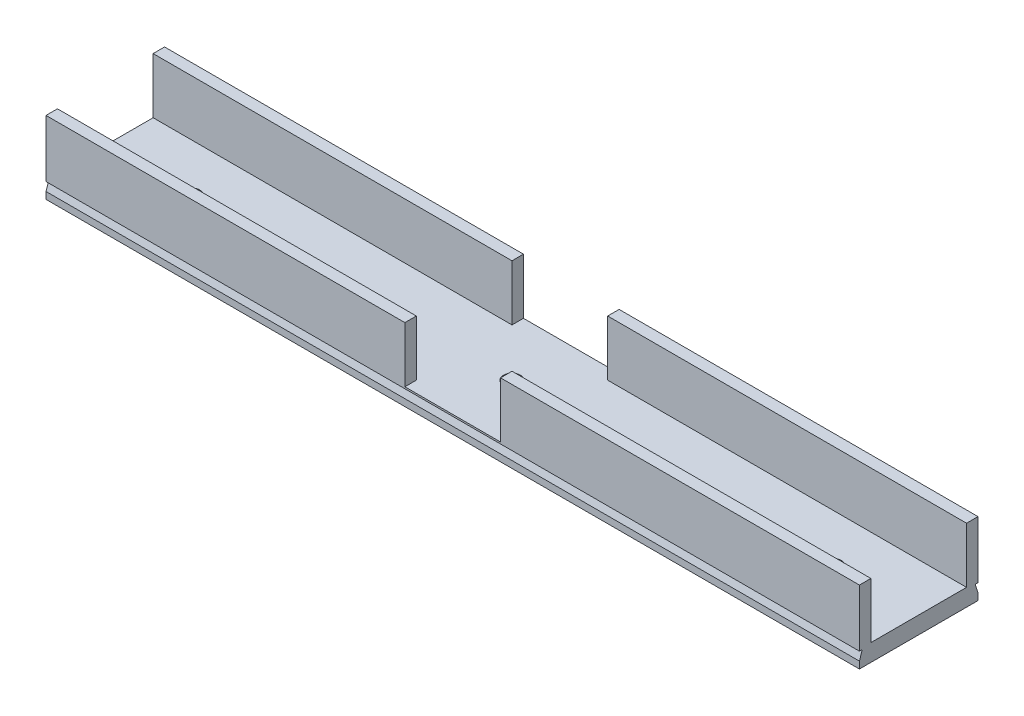
from build123d import *

# Parameters (mm, degrees)
CROQUIS1_W              = 142
CROQUIS1_H              = 20.7
SALIENTE_EXTRUIR2_DEPTH = 3
CROQUIS6_R              = 1.5
CORTAR_EXTRUIR4_DEPTH   = 3
CROQUIS7_W              = 142
CROQUIS7_H              = 2
SALIENTE_EXTRUIR3_DEPTH = 9.7
CORTAR_EXTRUIR5_DEPTH   = 224
CROQUIS10_W             = 16.7
CROQUIS10_H             = 9.7
CORTAR_EXTRUIR6_DEPTH   = 80


with BuildPart() as part:
    # Croquis1 → Saliente-Extruir2 (new body)
    with BuildSketch(Plane(origin=(0, 0, 0), x_dir=(1, 0, 0), z_dir=(0, 1, 0))):
        Rectangle(CROQUIS1_W, CROQUIS1_H)
    extrude(amount=SALIENTE_EXTRUIR2_DEPTH)

    # Croquis6 → Cortar-Extruir4 (cut)
    with BuildSketch(Plane(origin=(0, 3, 0), x_dir=(1, 0, 0), z_dir=(0, 1, 0))):
        with Locations((-56, 0)):
            Circle(CROQUIS6_R)
        Circle(CROQUIS6_R)
        with Locations((56, 0)):
            Circle(CROQUIS6_R)
    extrude(amount=-CORTAR_EXTRUIR4_DEPTH, mode=Mode.SUBTRACT)

    # Croquis7 → Saliente-Extruir3 (add)
    with BuildSketch(Plane(origin=(0, 3, 0), x_dir=(1, 0, 0), z_dir=(0, 1, 0))):
        with Locations((0, 9.35)):
            Rectangle(CROQUIS7_W, CROQUIS7_H)
        with Locations((0, -9.35)):
            Rectangle(CROQUIS7_W, CROQUIS7_H)
    extrude(amount=SALIENTE_EXTRUIR3_DEPTH)

    # Croquis9 → Cortar-Extruir5 (cut)
    with BuildSketch(Plane.ZY.offset(71)):
        Polygon((-10.35, 2.7), (-9.85, 2.7), (-10.35, 1.2), align=None)
        Polygon((10.35, 2.7), (9.85, 2.7), (10.35, 1.2), align=None)
    extrude(amount=-CORTAR_EXTRUIR5_DEPTH, mode=Mode.SUBTRACT)

    # Croquis10 → Cortar-Extruir6 (cut)
    with BuildSketch(Plane.XY.offset(10.35)):
        with Locations((0, 7.85)):
            Rectangle(CROQUIS10_W, CROQUIS10_H)
    extrude(amount=-CORTAR_EXTRUIR6_DEPTH, mode=Mode.SUBTRACT)


solid = part.part
